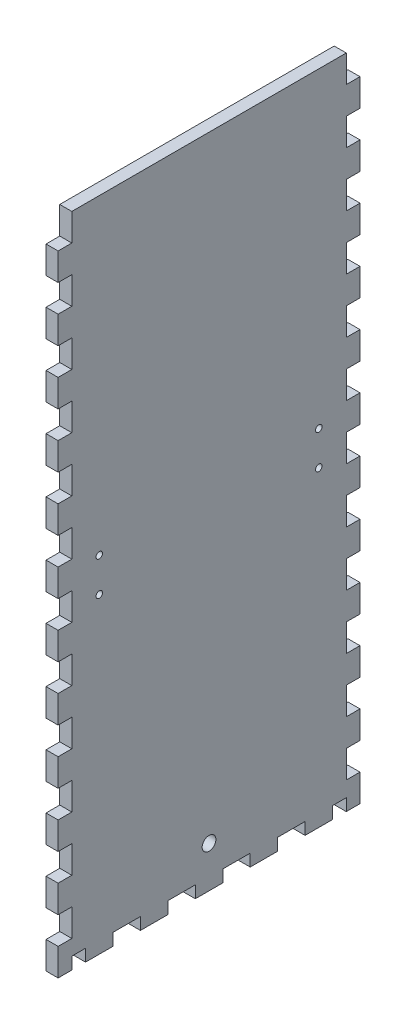
from build123d import *

# Parameters (mm, degrees)
SKETCH1_W              = 273.05
SKETCH1_H              = 139.7
BOSS_EXTRUDE1_DEPTH    = 5.588
SKETCH2_W              = 273.05
SKETCH2_H              = 139.7
SKETCH2_W_2            = 261.874
SKETCH2_H_2            = 128.524
BOSS_EXTRUDE2_DEPTH    = 298.45
SKETCH3_W              = 6.35
SKETCH3_H              = 16.933333333
SKETCH3_H_2            = 16.933333334
DOOR_SLOT_DEPTH        = 12.7
DOOR_GUIDE_HOLES_REACH = 361.255
SKETCH4_W              = 6.35
SKETCH4_H              = 15.875
LEVER_HOLES_W          = 9.652
LEVER_HOLES_H          = 6.35
LEVER_HOLES_W_2        = 6.35
CUT_EXTRUDE1_DEPTH     = 362.378293578
CUT_EXTRUDE2_REACH     = 416.577
SKETCH7_R              = 26.9875
CUT_EXTRUDE3_REACH     = 416.577
SKETCH8_R              = 3.175
SKETCH8_R_2            = 1.5
SKETCH16_W             = 336.893526087
SKETCH16_H             = 314.471565403
CUT_EXTRUDE10_DEPTH    = 362.378293578
LEFT_RIGHT_W           = 6.35
LEFT_RIGHT_H           = 5.588
LEFT_RIGHT_W_2         = 12.7
LEFT_RIGHT_H_2         = 12.66825
CUT_EXTRUDE11_DEPTH    = 313.00857951


with BuildPart() as part:
    # Sketch1 → Boss-Extrude1 (new body)
    with BuildSketch(Plane(origin=(0, 0, 0), x_dir=(1, 0, 0), z_dir=(0, 1, 0))):
        Rectangle(SKETCH1_W, SKETCH1_H)
    extrude(amount=BOSS_EXTRUDE1_DEPTH)

    # Sketch2 → Boss-Extrude2 (add)
    with BuildSketch(Plane(origin=(0, 5.588, 0), x_dir=(1, 0, 0), z_dir=(0, 1, 0))):
        Rectangle(SKETCH2_W, SKETCH2_H)
        Rectangle(SKETCH2_W_2, SKETCH2_H_2, mode=Mode.SUBTRACT)
    extrude(amount=BOSS_EXTRUDE2_DEPTH)

    # Sketch3 → Door Slot (cut)
    with BuildSketch(Plane.XY.offset(69.85)):
        with BuildLine():
            Line((-29.337, 282.448), (-29.337, 5.588))
            Line((-29.337, 5.588), (-22.733, 5.588))
            Line((-22.733, 5.588), (-22.733, 291.592))
            Line((-22.733, 291.592), (-42.291, 291.592))
            Line((-42.291, 291.592), (-42.291, 284.988))
            Line((-42.291, 284.988), (-31.877, 284.988))
            ThreePointArc((-31.877, 284.988), (-30.080948776, 284.244051224), (-29.337, 282.448))
        make_face()
        with Locations((-13.208, 80.433333334)):
            Rectangle(SKETCH3_W, SKETCH3_H)
        with Locations((-13.208, 50.8)):
            Rectangle(SKETCH3_W, SKETCH3_H_2)
        with Locations((-13.208, 21.166666667)):
            Rectangle(SKETCH3_W, SKETCH3_H)
    extrude(amount=-DOOR_SLOT_DEPTH, mode=Mode.SUBTRACT)

    # Sketch4 → Door Guide Holes (cut, up to next)
    with BuildSketch(Plane.XY.offset(-64.262), mode=Mode.PRIVATE) as door_guide_holes_sk1:
        with Locations((-45.466, 283.4005)):
            Rectangle(SKETCH4_W, SKETCH4_H)
    door_guide_holes_tool1 = extrude(door_guide_holes_sk1.sketch, amount=-DOOR_GUIDE_HOLES_REACH, mode=Mode.PRIVATE) & part.part
    # Sketch4 → Door Guide Holes (cut, up to next)
    with BuildSketch(Plane.XY.offset(-64.262), mode=Mode.PRIVATE) as door_guide_holes_sk2:
        with Locations((-45.466, 254.8255)):
            Rectangle(SKETCH4_W, SKETCH4_H)
    door_guide_holes_tool2 = extrude(door_guide_holes_sk2.sketch, amount=-DOOR_GUIDE_HOLES_REACH, mode=Mode.PRIVATE) & part.part
    # Sketch4 → Door Guide Holes (cut, up to next)
    with BuildSketch(Plane.XY.offset(-64.262), mode=Mode.PRIVATE) as door_guide_holes_sk3:
        with Locations((-45.466, 226.2505)):
            Rectangle(SKETCH4_W, SKETCH4_H)
    door_guide_holes_tool3 = extrude(door_guide_holes_sk3.sketch, amount=-DOOR_GUIDE_HOLES_REACH, mode=Mode.PRIVATE) & part.part
    # Sketch4 → Door Guide Holes (cut, up to next)
    with BuildSketch(Plane.XY.offset(-64.262), mode=Mode.PRIVATE) as door_guide_holes_sk4:
        with Locations((-45.466, 197.6755)):
            Rectangle(SKETCH4_W, SKETCH4_H)
    door_guide_holes_tool4 = extrude(door_guide_holes_sk4.sketch, amount=-DOOR_GUIDE_HOLES_REACH, mode=Mode.PRIVATE) & part.part
    # Sketch4 → Door Guide Holes (cut, up to next)
    with BuildSketch(Plane.XY.offset(-64.262), mode=Mode.PRIVATE) as door_guide_holes_sk5:
        with Locations((-45.466, 169.1005)):
            Rectangle(SKETCH4_W, SKETCH4_H)
    door_guide_holes_tool5 = extrude(door_guide_holes_sk5.sketch, amount=-DOOR_GUIDE_HOLES_REACH, mode=Mode.PRIVATE) & part.part
    # Sketch4 → Door Guide Holes (cut, up to next)
    with BuildSketch(Plane.XY.offset(-64.262), mode=Mode.PRIVATE) as door_guide_holes_sk6:
        with Locations((-45.466, 140.5255)):
            Rectangle(SKETCH4_W, SKETCH4_H)
    door_guide_holes_tool6 = extrude(door_guide_holes_sk6.sketch, amount=-DOOR_GUIDE_HOLES_REACH, mode=Mode.PRIVATE) & part.part
    # Sketch4 → Door Guide Holes (cut, up to next)
    with BuildSketch(Plane.XY.offset(-64.262), mode=Mode.PRIVATE) as door_guide_holes_sk7:
        with Locations((-45.466, 111.9505)):
            Rectangle(SKETCH4_W, SKETCH4_H)
    door_guide_holes_tool7 = extrude(door_guide_holes_sk7.sketch, amount=-DOOR_GUIDE_HOLES_REACH, mode=Mode.PRIVATE) & part.part
    # Sketch4 → Door Guide Holes (cut, up to next)
    with BuildSketch(Plane.XY.offset(-64.262), mode=Mode.PRIVATE) as door_guide_holes_sk8:
        with Locations((-45.466, 83.3755)):
            Rectangle(SKETCH4_W, SKETCH4_H)
    door_guide_holes_tool8 = extrude(door_guide_holes_sk8.sketch, amount=-DOOR_GUIDE_HOLES_REACH, mode=Mode.PRIVATE) & part.part
    # Sketch4 → Door Guide Holes (cut, up to next)
    with BuildSketch(Plane.XY.offset(-64.262), mode=Mode.PRIVATE) as door_guide_holes_sk9:
        with Locations((-45.466, 54.8005)):
            Rectangle(SKETCH4_W, SKETCH4_H)
    door_guide_holes_tool9 = extrude(door_guide_holes_sk9.sketch, amount=-DOOR_GUIDE_HOLES_REACH, mode=Mode.PRIVATE) & part.part
    # Sketch4 → Door Guide Holes (cut, up to next)
    with BuildSketch(Plane.XY.offset(-64.262), mode=Mode.PRIVATE) as door_guide_holes_sk10:
        with Locations((-45.466, 26.2255)):
            Rectangle(SKETCH4_W, SKETCH4_H)
    door_guide_holes_tool10 = extrude(door_guide_holes_sk10.sketch, amount=-DOOR_GUIDE_HOLES_REACH, mode=Mode.PRIVATE) & part.part
    door_guide_holes_1 = door_guide_holes_tool1.solids().sort_by_distance((-45.466, 283.4005, -64.262))[0]
    add(door_guide_holes_1, mode=Mode.SUBTRACT)
    door_guide_holes_2 = door_guide_holes_tool2.solids().sort_by_distance((-45.466, 254.8255, -64.262))[0]
    add(door_guide_holes_2, mode=Mode.SUBTRACT)
    door_guide_holes_3 = door_guide_holes_tool3.solids().sort_by_distance((-45.466, 226.2505, -64.262))[0]
    add(door_guide_holes_3, mode=Mode.SUBTRACT)
    door_guide_holes_4 = door_guide_holes_tool4.solids().sort_by_distance((-45.466, 197.6755, -64.262))[0]
    add(door_guide_holes_4, mode=Mode.SUBTRACT)
    door_guide_holes_5 = door_guide_holes_tool5.solids().sort_by_distance((-45.466, 169.1005, -64.262))[0]
    add(door_guide_holes_5, mode=Mode.SUBTRACT)
    door_guide_holes_6 = door_guide_holes_tool6.solids().sort_by_distance((-45.466, 140.5255, -64.262))[0]
    add(door_guide_holes_6, mode=Mode.SUBTRACT)
    door_guide_holes_7 = door_guide_holes_tool7.solids().sort_by_distance((-45.466, 111.9505, -64.262))[0]
    add(door_guide_holes_7, mode=Mode.SUBTRACT)
    door_guide_holes_8 = door_guide_holes_tool8.solids().sort_by_distance((-45.466, 83.3755, -64.262))[0]
    add(door_guide_holes_8, mode=Mode.SUBTRACT)
    door_guide_holes_9 = door_guide_holes_tool9.solids().sort_by_distance((-45.466, 54.8005, -64.262))[0]
    add(door_guide_holes_9, mode=Mode.SUBTRACT)
    door_guide_holes_10 = door_guide_holes_tool10.solids().sort_by_distance((-45.466, 26.2255, -64.262))[0]
    add(door_guide_holes_10, mode=Mode.SUBTRACT)
    door_guide_holes = door_guide_holes_1 + door_guide_holes_2 + door_guide_holes_3 + door_guide_holes_4 + door_guide_holes_5 + door_guide_holes_6 + door_guide_holes_7 + door_guide_holes_8 + door_guide_holes_9 + door_guide_holes_10  # Door Guide Holes as one shape, for the pattern or mirror that repeats it

    # Mirror1: Door Guide Holes across plane
    add(door_guide_holes.mirror(Plane.ZY.offset(32.512)), mode=Mode.SUBTRACT)

    # Lever Holes → Cut-Extrude1 (cut, through all)
    with BuildSketch(Plane.XY.offset(69.85)):
        with Locations((54.102, 28.575)):
            Rectangle(LEVER_HOLES_W, LEVER_HOLES_H)
        with Locations((39.3065, 15.875)):
            Rectangle(LEVER_HOLES_W_2, LEVER_HOLES_H)
        with Locations((68.8975, 15.875)):
            Rectangle(LEVER_HOLES_W_2, LEVER_HOLES_H)
    extrude(amount=-CUT_EXTRUDE1_DEPTH, mode=Mode.SUBTRACT)

    # Sketch7 → Cut-Extrude2 (cut, up to next)
    with BuildSketch(Plane(origin=(136.525, 0, 0), x_dir=(0, 0, -1), z_dir=(1, 0, 0)), mode=Mode.PRIVATE) as cut_extrude2_sk1:
        with Locations((0, 55.372)):
            Circle(SKETCH7_R)
    cut_extrude2_tool1 = extrude(cut_extrude2_sk1.sketch, amount=-CUT_EXTRUDE2_REACH, mode=Mode.PRIVATE) & part.part
    # Sketch7 → Cut-Extrude2 (cut, up to next)
    with BuildSketch(Plane(origin=(136.525, 0, 0), x_dir=(0, 0, -1), z_dir=(1, 0, 0)), mode=Mode.PRIVATE) as cut_extrude2_sk2:
        with BuildLine():
            Line((-37.211, 89.408), (-37.211, 92.583))
            Line((-37.211, 92.583), (-34.036, 92.583))
            ThreePointArc((-34.036, 92.583), (-39.45606403, 94.82806403), (-37.211, 89.408))
        make_face()
    cut_extrude2_tool2 = extrude(cut_extrude2_sk2.sketch, amount=-CUT_EXTRUDE2_REACH, mode=Mode.PRIVATE) & part.part
    # Sketch7 → Cut-Extrude2 (cut, up to next)
    with BuildSketch(Plane(origin=(136.525, 0, 0), x_dir=(0, 0, -1), z_dir=(1, 0, 0)), mode=Mode.PRIVATE) as cut_extrude2_sk3:
        with BuildLine():
            Line((-34.036, 92.583), (-37.211, 92.583))
            Line((-37.211, 92.583), (-37.211, 89.408))
            ThreePointArc((-37.211, 89.408), (-34.96593597, 90.33793597), (-34.036, 92.583))
        make_face()
    cut_extrude2_tool3 = extrude(cut_extrude2_sk3.sketch, amount=-CUT_EXTRUDE2_REACH, mode=Mode.PRIVATE) & part.part
    # Sketch7 → Cut-Extrude2 (cut, up to next)
    with BuildSketch(Plane(origin=(136.525, 0, 0), x_dir=(0, 0, -1), z_dir=(1, 0, 0)), mode=Mode.PRIVATE) as cut_extrude2_sk4:
        with BuildLine():
            Line((-37.211, 89.408), (-37.211, 92.583))
            Line((-37.211, 92.583), (-34.036, 92.583))
            ThreePointArc((-34.036, 92.583), (-39.45606403, 94.82806403), (-37.211, 89.408))
        make_face()
    cut_extrude2_tool4 = extrude(cut_extrude2_sk4.sketch, amount=-CUT_EXTRUDE2_REACH, mode=Mode.PRIVATE) & part.part
    # Sketch7 → Cut-Extrude2 (cut, up to next)
    with BuildSketch(Plane(origin=(136.525, 0, 0), x_dir=(0, 0, -1), z_dir=(1, 0, 0)), mode=Mode.PRIVATE) as cut_extrude2_sk5:
        with BuildLine():
            Line((-34.036, 92.583), (-37.211, 92.583))
            Line((-37.211, 92.583), (-37.211, 89.408))
            ThreePointArc((-37.211, 89.408), (-34.96593597, 90.33793597), (-34.036, 92.583))
        make_face()
    cut_extrude2_tool5 = extrude(cut_extrude2_sk5.sketch, amount=-CUT_EXTRUDE2_REACH, mode=Mode.PRIVATE) & part.part
    # Sketch7 → Cut-Extrude2 (cut, up to next)
    with BuildSketch(Plane(origin=(136.525, 0, 0), x_dir=(0, 0, -1), z_dir=(1, 0, 0)), mode=Mode.PRIVATE) as cut_extrude2_sk6:
        with BuildLine():
            ThreePointArc((40.386, 92.583), (37.211, 95.758), (34.036, 92.583))
            Line((34.036, 92.583), (37.211, 92.583))
            Line((37.211, 92.583), (37.211, 89.408))
            ThreePointArc((37.211, 89.408), (39.45606403, 90.33793597), (40.386, 92.583))
        make_face()
    cut_extrude2_tool6 = extrude(cut_extrude2_sk6.sketch, amount=-CUT_EXTRUDE2_REACH, mode=Mode.PRIVATE) & part.part
    # Sketch7 → Cut-Extrude2 (cut, up to next)
    with BuildSketch(Plane(origin=(136.525, 0, 0), x_dir=(0, 0, -1), z_dir=(1, 0, 0)), mode=Mode.PRIVATE) as cut_extrude2_sk7:
        with BuildLine():
            Line((37.211, 92.583), (34.036, 92.583))
            ThreePointArc((34.036, 92.583), (34.96593597, 90.33793597), (37.211, 89.408))
            Line((37.211, 89.408), (37.211, 92.583))
        make_face()
    cut_extrude2_tool7 = extrude(cut_extrude2_sk7.sketch, amount=-CUT_EXTRUDE2_REACH, mode=Mode.PRIVATE) & part.part
    # Sketch7 → Cut-Extrude2 (cut, up to next)
    with BuildSketch(Plane(origin=(136.525, 0, 0), x_dir=(0, 0, -1), z_dir=(1, 0, 0)), mode=Mode.PRIVATE) as cut_extrude2_sk8:
        with BuildLine():
            ThreePointArc((40.386, 92.583), (37.211, 95.758), (34.036, 92.583))
            Line((34.036, 92.583), (37.211, 92.583))
            Line((37.211, 92.583), (37.211, 89.408))
            ThreePointArc((37.211, 89.408), (39.45606403, 90.33793597), (40.386, 92.583))
        make_face()
    cut_extrude2_tool8 = extrude(cut_extrude2_sk8.sketch, amount=-CUT_EXTRUDE2_REACH, mode=Mode.PRIVATE) & part.part
    # Sketch7 → Cut-Extrude2 (cut, up to next)
    with BuildSketch(Plane(origin=(136.525, 0, 0), x_dir=(0, 0, -1), z_dir=(1, 0, 0)), mode=Mode.PRIVATE) as cut_extrude2_sk9:
        with BuildLine():
            Line((37.211, 92.583), (34.036, 92.583))
            ThreePointArc((34.036, 92.583), (34.96593597, 90.33793597), (37.211, 89.408))
            Line((37.211, 89.408), (37.211, 92.583))
        make_face()
    cut_extrude2_tool9 = extrude(cut_extrude2_sk9.sketch, amount=-CUT_EXTRUDE2_REACH, mode=Mode.PRIVATE) & part.part
    # Sketch7 → Cut-Extrude2 (cut, up to next)
    with BuildSketch(Plane(origin=(136.525, 0, 0), x_dir=(0, 0, -1), z_dir=(1, 0, 0)), mode=Mode.PRIVATE) as cut_extrude2_sk10:
        with BuildLine():
            ThreePointArc((-34.036, 18.161), (-34.96593597, 20.40606403), (-37.211, 21.336))
            Line((-37.211, 21.336), (-37.211, 18.161))
            Line((-37.211, 18.161), (-34.036, 18.161))
        make_face()
    cut_extrude2_tool10 = extrude(cut_extrude2_sk10.sketch, amount=-CUT_EXTRUDE2_REACH, mode=Mode.PRIVATE) & part.part
    # Sketch7 → Cut-Extrude2 (cut, up to next)
    with BuildSketch(Plane(origin=(136.525, 0, 0), x_dir=(0, 0, -1), z_dir=(1, 0, 0)), mode=Mode.PRIVATE) as cut_extrude2_sk11:
        with BuildLine():
            Line((-37.211, 18.161), (-37.211, 21.336))
            ThreePointArc((-37.211, 21.336), (-39.45606403, 15.91593597), (-34.036, 18.161))
            Line((-34.036, 18.161), (-37.211, 18.161))
        make_face()
    cut_extrude2_tool11 = extrude(cut_extrude2_sk11.sketch, amount=-CUT_EXTRUDE2_REACH, mode=Mode.PRIVATE) & part.part
    # Sketch7 → Cut-Extrude2 (cut, up to next)
    with BuildSketch(Plane(origin=(136.525, 0, 0), x_dir=(0, 0, -1), z_dir=(1, 0, 0)), mode=Mode.PRIVATE) as cut_extrude2_sk12:
        with BuildLine():
            ThreePointArc((-34.036, 18.161), (-34.96593597, 20.40606403), (-37.211, 21.336))
            Line((-37.211, 21.336), (-37.211, 18.161))
            Line((-37.211, 18.161), (-34.036, 18.161))
        make_face()
    cut_extrude2_tool12 = extrude(cut_extrude2_sk12.sketch, amount=-CUT_EXTRUDE2_REACH, mode=Mode.PRIVATE) & part.part
    # Sketch7 → Cut-Extrude2 (cut, up to next)
    with BuildSketch(Plane(origin=(136.525, 0, 0), x_dir=(0, 0, -1), z_dir=(1, 0, 0)), mode=Mode.PRIVATE) as cut_extrude2_sk13:
        with BuildLine():
            Line((-37.211, 18.161), (-37.211, 21.336))
            ThreePointArc((-37.211, 21.336), (-39.45606403, 15.91593597), (-34.036, 18.161))
            Line((-34.036, 18.161), (-37.211, 18.161))
        make_face()
    cut_extrude2_tool13 = extrude(cut_extrude2_sk13.sketch, amount=-CUT_EXTRUDE2_REACH, mode=Mode.PRIVATE) & part.part
    # Sketch7 → Cut-Extrude2 (cut, up to next)
    with BuildSketch(Plane(origin=(136.525, 0, 0), x_dir=(0, 0, -1), z_dir=(1, 0, 0)), mode=Mode.PRIVATE) as cut_extrude2_sk14:
        with BuildLine():
            ThreePointArc((40.386, 18.161), (39.45606403, 20.40606403), (37.211, 21.336))
            Line((37.211, 21.336), (37.211, 18.161))
            Line((37.211, 18.161), (34.036, 18.161))
            ThreePointArc((34.036, 18.161), (37.211, 14.986), (40.386, 18.161))
        make_face()
    cut_extrude2_tool14 = extrude(cut_extrude2_sk14.sketch, amount=-CUT_EXTRUDE2_REACH, mode=Mode.PRIVATE) & part.part
    # Sketch7 → Cut-Extrude2 (cut, up to next)
    with BuildSketch(Plane(origin=(136.525, 0, 0), x_dir=(0, 0, -1), z_dir=(1, 0, 0)), mode=Mode.PRIVATE) as cut_extrude2_sk15:
        with BuildLine():
            Line((37.211, 18.161), (37.211, 21.336))
            ThreePointArc((37.211, 21.336), (34.96593597, 20.40606403), (34.036, 18.161))
            Line((34.036, 18.161), (37.211, 18.161))
        make_face()
    cut_extrude2_tool15 = extrude(cut_extrude2_sk15.sketch, amount=-CUT_EXTRUDE2_REACH, mode=Mode.PRIVATE) & part.part
    # Sketch7 → Cut-Extrude2 (cut, up to next)
    with BuildSketch(Plane(origin=(136.525, 0, 0), x_dir=(0, 0, -1), z_dir=(1, 0, 0)), mode=Mode.PRIVATE) as cut_extrude2_sk16:
        with BuildLine():
            ThreePointArc((40.386, 18.161), (39.45606403, 20.40606403), (37.211, 21.336))
            Line((37.211, 21.336), (37.211, 18.161))
            Line((37.211, 18.161), (34.036, 18.161))
            ThreePointArc((34.036, 18.161), (37.211, 14.986), (40.386, 18.161))
        make_face()
    cut_extrude2_tool16 = extrude(cut_extrude2_sk16.sketch, amount=-CUT_EXTRUDE2_REACH, mode=Mode.PRIVATE) & part.part
    # Sketch7 → Cut-Extrude2 (cut, up to next)
    with BuildSketch(Plane(origin=(136.525, 0, 0), x_dir=(0, 0, -1), z_dir=(1, 0, 0)), mode=Mode.PRIVATE) as cut_extrude2_sk17:
        with BuildLine():
            Line((37.211, 18.161), (37.211, 21.336))
            ThreePointArc((37.211, 21.336), (34.96593597, 20.40606403), (34.036, 18.161))
            Line((34.036, 18.161), (37.211, 18.161))
        make_face()
    cut_extrude2_tool17 = extrude(cut_extrude2_sk17.sketch, amount=-CUT_EXTRUDE2_REACH, mode=Mode.PRIVATE) & part.part
    add(cut_extrude2_tool1.solids().sort_by_distance((136.525, 55.372, 0))[0], mode=Mode.SUBTRACT)
    add(cut_extrude2_tool2.solids().sort_by_distance((136.525, 93.032171, 37.660171))[0], mode=Mode.SUBTRACT)
    add(cut_extrude2_tool3.solids().sort_by_distance((136.525, 91.235488, 35.863488))[0], mode=Mode.SUBTRACT)
    add(cut_extrude2_tool4.solids().sort_by_distance((136.525, 93.032171, 37.660171))[0], mode=Mode.SUBTRACT)
    add(cut_extrude2_tool5.solids().sort_by_distance((136.525, 91.235488, 35.863488))[0], mode=Mode.SUBTRACT)
    add(cut_extrude2_tool6.solids().sort_by_distance((136.525, 93.032171, -37.660171))[0], mode=Mode.SUBTRACT)
    add(cut_extrude2_tool7.solids().sort_by_distance((136.525, 91.235488, -35.863488))[0], mode=Mode.SUBTRACT)
    add(cut_extrude2_tool8.solids().sort_by_distance((136.525, 93.032171, -37.660171))[0], mode=Mode.SUBTRACT)
    add(cut_extrude2_tool9.solids().sort_by_distance((136.525, 91.235488, -35.863488))[0], mode=Mode.SUBTRACT)
    add(cut_extrude2_tool10.solids().sort_by_distance((136.525, 19.508512, 35.863488))[0], mode=Mode.SUBTRACT)
    add(cut_extrude2_tool11.solids().sort_by_distance((136.525, 17.711829, 37.660171))[0], mode=Mode.SUBTRACT)
    add(cut_extrude2_tool12.solids().sort_by_distance((136.525, 19.508512, 35.863488))[0], mode=Mode.SUBTRACT)
    add(cut_extrude2_tool13.solids().sort_by_distance((136.525, 17.711829, 37.660171))[0], mode=Mode.SUBTRACT)
    add(cut_extrude2_tool14.solids().sort_by_distance((136.525, 17.711829, -37.660171))[0], mode=Mode.SUBTRACT)
    add(cut_extrude2_tool15.solids().sort_by_distance((136.525, 19.508512, -35.863488))[0], mode=Mode.SUBTRACT)
    add(cut_extrude2_tool16.solids().sort_by_distance((136.525, 17.711829, -37.660171))[0], mode=Mode.SUBTRACT)
    add(cut_extrude2_tool17.solids().sort_by_distance((136.525, 19.508512, -35.863488))[0], mode=Mode.SUBTRACT)

    # Sketch8 → Cut-Extrude3 (cut, up to next)
    with BuildSketch(Plane.ZY.offset(136.525), mode=Mode.PRIVATE) as cut_extrude3_sk1:
        with Locations((0, 19.05)):
            Circle(SKETCH8_R)
    cut_extrude3_tool1 = extrude(cut_extrude3_sk1.sketch, amount=-CUT_EXTRUDE3_REACH, mode=Mode.PRIVATE) & part.part
    # Sketch8 → Cut-Extrude3 (cut, up to next)
    with BuildSketch(Plane.ZY.offset(136.525), mode=Mode.PRIVATE) as cut_extrude3_sk2:
        with Locations((-50.8, 159.894)):
            Circle(SKETCH8_R_2)
    cut_extrude3_tool2 = extrude(cut_extrude3_sk2.sketch, amount=-CUT_EXTRUDE3_REACH, mode=Mode.PRIVATE) & part.part
    # Sketch8 → Cut-Extrude3 (cut, up to next)
    with BuildSketch(Plane.ZY.offset(136.525), mode=Mode.PRIVATE) as cut_extrude3_sk3:
        with Locations((-50.8, 144.144)):
            Circle(SKETCH8_R_2)
    cut_extrude3_tool3 = extrude(cut_extrude3_sk3.sketch, amount=-CUT_EXTRUDE3_REACH, mode=Mode.PRIVATE) & part.part
    # Sketch8 → Cut-Extrude3 (cut, up to next)
    with BuildSketch(Plane.ZY.offset(136.525), mode=Mode.PRIVATE) as cut_extrude3_sk4:
        with Locations(Location((50.8, 144.144, 0), (0, 0, 180))):
            Circle(SKETCH8_R_2)
    cut_extrude3_tool4 = extrude(cut_extrude3_sk4.sketch, amount=-CUT_EXTRUDE3_REACH, mode=Mode.PRIVATE) & part.part
    # Sketch8 → Cut-Extrude3 (cut, up to next)
    with BuildSketch(Plane.ZY.offset(136.525), mode=Mode.PRIVATE) as cut_extrude3_sk5:
        with Locations(Location((50.8, 159.894, 0), (0, 0, 180))):
            Circle(SKETCH8_R_2)
    cut_extrude3_tool5 = extrude(cut_extrude3_sk5.sketch, amount=-CUT_EXTRUDE3_REACH, mode=Mode.PRIVATE) & part.part
    add(cut_extrude3_tool1.solids().sort_by_distance((-136.525, 19.05, 0))[0], mode=Mode.SUBTRACT)
    add(cut_extrude3_tool2.solids().sort_by_distance((-136.525, 159.894, -50.8))[0], mode=Mode.SUBTRACT)
    add(cut_extrude3_tool3.solids().sort_by_distance((-136.525, 144.144, -50.8))[0], mode=Mode.SUBTRACT)
    add(cut_extrude3_tool4.solids().sort_by_distance((-136.525, 144.144, 50.8))[0], mode=Mode.SUBTRACT)
    add(cut_extrude3_tool5.solids().sort_by_distance((-136.525, 159.894, 50.8))[0], mode=Mode.SUBTRACT)

    # Sketch16 → Cut-Extrude10 (cut, through all)
    with BuildSketch(Plane.XY.offset(69.85)):
        with Locations((37.509763044, 146.802217299)):
            Rectangle(SKETCH16_W, SKETCH16_H)
    extrude(amount=-CUT_EXTRUDE10_DEPTH, mode=Mode.SUBTRACT)

    # Left/Right → Cut-Extrude11 (cut, through all)
    with BuildSketch(Plane.ZY.offset(136.525)):
        with Locations((60.325, 2.794)):
            Rectangle(LEFT_RIGHT_W, LEFT_RIGHT_H)
        with Locations((38.1, 2.794)):
            Rectangle(LEFT_RIGHT_W_2, LEFT_RIGHT_H)
        with Locations((66.675, 19.002375)):
            Rectangle(LEFT_RIGHT_W, LEFT_RIGHT_H_2)
        with Locations((12.7, 2.794)):
            Rectangle(LEFT_RIGHT_W_2, LEFT_RIGHT_H)
        with Locations((66.675, 44.338875)):
            Rectangle(LEFT_RIGHT_W, LEFT_RIGHT_H_2)
        with Locations((-12.7, 2.794)):
            Rectangle(LEFT_RIGHT_W_2, LEFT_RIGHT_H)
        with Locations((66.675, 69.675375)):
            Rectangle(LEFT_RIGHT_W, LEFT_RIGHT_H_2)
        with Locations((-38.1, 2.794)):
            Rectangle(LEFT_RIGHT_W_2, LEFT_RIGHT_H)
        with Locations((66.675, 95.011875)):
            Rectangle(LEFT_RIGHT_W, LEFT_RIGHT_H_2)
        with Locations((-60.325, 2.794)):
            Rectangle(LEFT_RIGHT_W, LEFT_RIGHT_H)
        with Locations((66.675, 120.348375)):
            Rectangle(LEFT_RIGHT_W, LEFT_RIGHT_H_2)
        with Locations((-66.675, 19.002375)):
            Rectangle(LEFT_RIGHT_W, LEFT_RIGHT_H_2)
        with Locations((66.675, 145.684875)):
            Rectangle(LEFT_RIGHT_W, LEFT_RIGHT_H_2)
        with Locations((-66.675, 44.338875)):
            Rectangle(LEFT_RIGHT_W, LEFT_RIGHT_H_2)
        with Locations((66.675, 171.021375)):
            Rectangle(LEFT_RIGHT_W, LEFT_RIGHT_H_2)
        with Locations((-66.675, 69.675375)):
            Rectangle(LEFT_RIGHT_W, LEFT_RIGHT_H_2)
        with Locations((66.675, 196.357875)):
            Rectangle(LEFT_RIGHT_W, LEFT_RIGHT_H_2)
        with Locations((-66.675, 95.011875)):
            Rectangle(LEFT_RIGHT_W, LEFT_RIGHT_H_2)
        with Locations((66.675, 221.694375)):
            Rectangle(LEFT_RIGHT_W, LEFT_RIGHT_H_2)
        with Locations((-66.675, 120.348375)):
            Rectangle(LEFT_RIGHT_W, LEFT_RIGHT_H_2)
        with Locations((66.675, 247.030875)):
            Rectangle(LEFT_RIGHT_W, LEFT_RIGHT_H_2)
        with Locations((-66.675, 145.684875)):
            Rectangle(LEFT_RIGHT_W, LEFT_RIGHT_H_2)
        with Locations((66.675, 272.367375)):
            Rectangle(LEFT_RIGHT_W, LEFT_RIGHT_H_2)
        with Locations((-66.675, 171.021375)):
            Rectangle(LEFT_RIGHT_W, LEFT_RIGHT_H_2)
        with Locations((66.675, 297.703875)):
            Rectangle(LEFT_RIGHT_W, LEFT_RIGHT_H_2)
        with Locations((-66.675, 196.357875)):
            Rectangle(LEFT_RIGHT_W, LEFT_RIGHT_H_2)
        with Locations((-66.675, 221.694375)):
            Rectangle(LEFT_RIGHT_W, LEFT_RIGHT_H_2)
        with Locations((-66.675, 247.030875)):
            Rectangle(LEFT_RIGHT_W, LEFT_RIGHT_H_2)
        with Locations((-66.675, 272.367375)):
            Rectangle(LEFT_RIGHT_W, LEFT_RIGHT_H_2)
        with Locations((-66.675, 297.703875)):
            Rectangle(LEFT_RIGHT_W, LEFT_RIGHT_H_2)
    extrude(amount=-CUT_EXTRUDE11_DEPTH, mode=Mode.SUBTRACT)


solid = part.part
